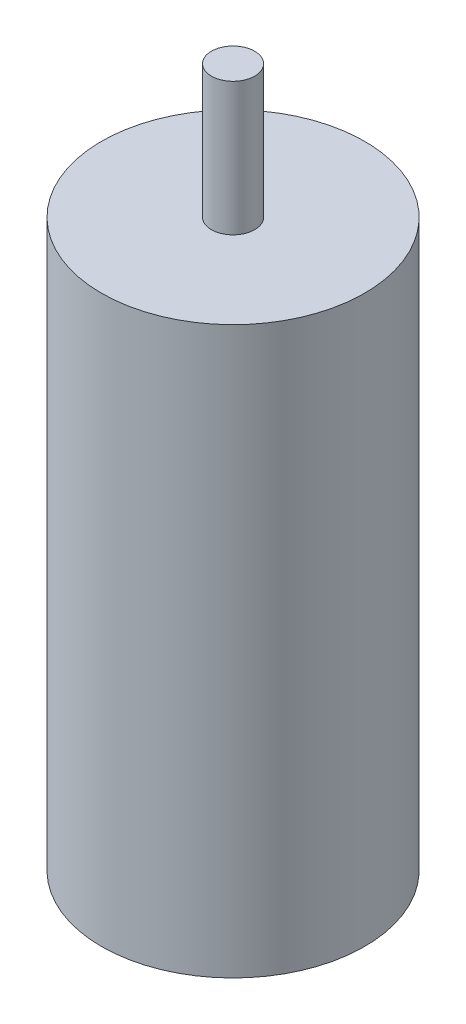
from build123d import *

# Parameters (mm, degrees)
SKETCH1_R           = 12.09675
BOSS_EXTRUDE1_DEPTH = 52.0192
SKETCH2_R           = 1.98755
BOSS_EXTRUDE2_DEPTH = 12.2301


with BuildPart() as part:
    # Sketch1 → Boss-Extrude1 (new body)
    with BuildSketch(Plane(origin=(0, 0, 0), x_dir=(1, 0, 0), z_dir=(0, 1, 0))):
        Circle(SKETCH1_R)
    extrude(amount=BOSS_EXTRUDE1_DEPTH)

    # Sketch2 → Boss-Extrude2 (add)
    with BuildSketch(Plane(origin=(0, 52.0192, 0), x_dir=(1, 0, 0), z_dir=(0, 1, 0))):
        Circle(SKETCH2_R)
    extrude(amount=BOSS_EXTRUDE2_DEPTH)


solid = part.part
